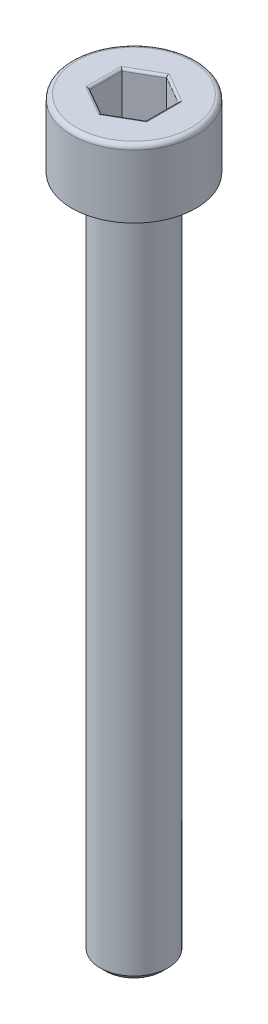
from build123d import *

# Parameters (mm, degrees)
CHAMFER1_SIZE      = 0.25
FILLET1_R          = 0.2
CUT_EXTRUDE1_DEPTH = 2
FILLET2_R          = 0.1


with BuildPart() as part:
    # Sketch1 → Revolve1 (revolve)
    with BuildSketch(Plane.XY):
        Polygon((0, -33), (-1.5, -33), (-1.5, -3), (-2.75, -3), (-2.75, 0), (0, 0), align=None)
    revolve(axis=Axis((0, 0, 0), (0, -1, 0)))

    # Chamfer1
    chamfer1_edges = [part.edges().sort_by_distance(p)[0] for p in [
        (1.5, -3, 0),
        (1.5, -33, 0),
    ]]
    chamfer(chamfer1_edges, length=CHAMFER1_SIZE)

    # Fillet1
    fillet1_edges = [part.edges().sort_by_distance(p)[0] for p in [
        (2.75, 0, 0),
    ]]
    fillet(fillet1_edges, radius=FILLET1_R)

    # Sketch2 → Cut-Extrude1 (cut)
    with BuildSketch(Plane(origin=(0, 0, 0), x_dir=(1, 0, 0), z_dir=(0, 1, 0))):
        Polygon((0, 1.443375673), (-1.25, 0.721687836), (-1.25, -0.721687836), (0, -1.443375673), (1.25, -0.721687836), (1.25, 0.721687836), align=None)
    extrude(amount=-CUT_EXTRUDE1_DEPTH, mode=Mode.SUBTRACT)

    # Fillet2
    fillet2_edges = [part.edges().sort_by_distance(p)[0] for p in [
        (0.625, -2, -1.082531755),
        (1.25, -2, 0),
        (0.625, -2, 1.082531755),
        (-0.625, -2, 1.082531755),
        (-1.25, -2, 0),
        (-0.625, -2, -1.082531755),
        (0.625, 0, -1.082531755),
        (-0.625, 0, -1.082531755),
        (-1.25, 0, 0),
        (-0.625, 0, 1.082531755),
        (0.625, 0, 1.082531755),
        (1.25, 0, 0),
    ]]
    fillet(fillet2_edges, radius=FILLET2_R)


solid = part.part
